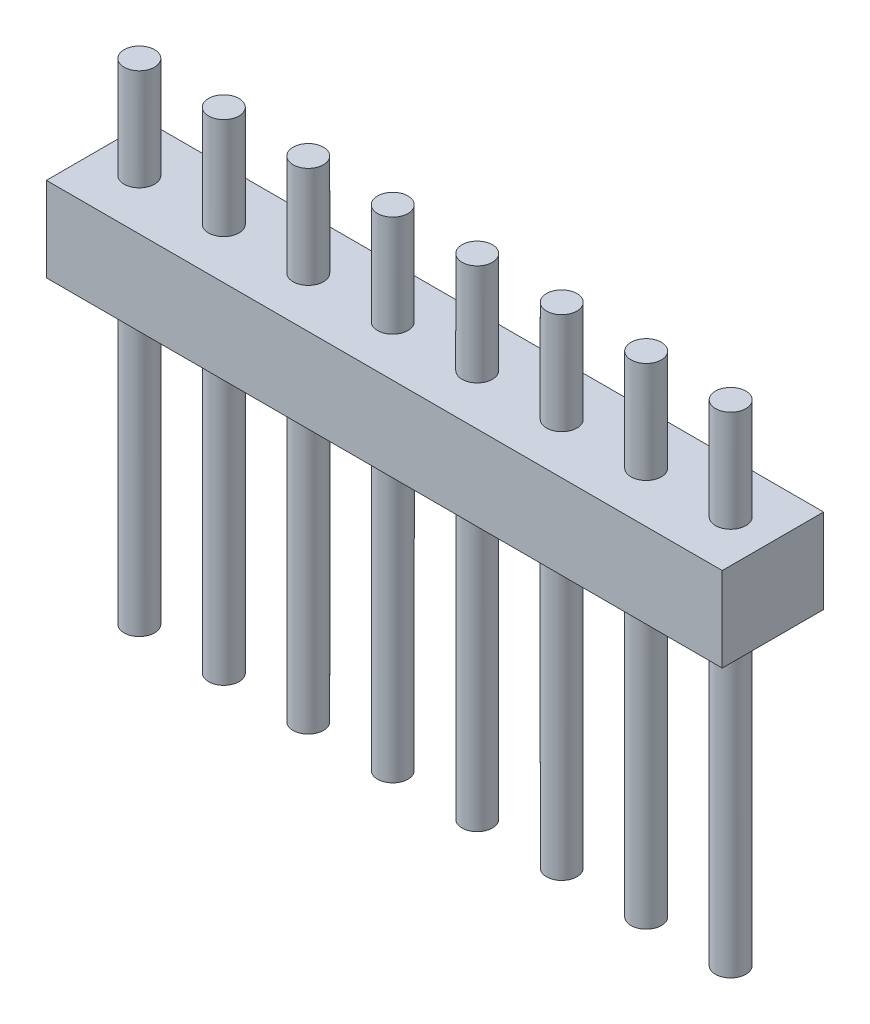
from build123d import *

# Parameters (mm, degrees)
CROQUIS1_W              = 20
CROQUIS1_H              = 2.5
SALIENTE_EXTRUIR1_DEPTH = 3
CROQUIS2_R              = 0.45
SALIENTE_EXTRUIR2_DEPTH = 3
CROQUIS3_R              = 0.45
SALIENTE_EXTRUIR3_DEPTH = 9


with BuildPart() as part:
    # Croquis1 → Saliente-Extruir1 (new body)
    with BuildSketch(Plane.XY):
        Rectangle(CROQUIS1_W, CROQUIS1_H)
    extrude(amount=SALIENTE_EXTRUIR1_DEPTH)

    # Croquis2 → Saliente-Extruir2 (add)
    with BuildSketch(Plane(origin=(0, 1.25, 0), x_dir=(1, 0, 0), z_dir=(0, 1, 0))):
        with Locations((-8.75, -1.5)):
            Circle(CROQUIS2_R)
        with Locations((-6.25, -1.5)):
            Circle(CROQUIS2_R)
        with Locations((-3.75, -1.5)):
            Circle(CROQUIS2_R)
        with Locations((-1.25, -1.5)):
            Circle(CROQUIS2_R)
        with Locations((1.25, -1.5)):
            Circle(CROQUIS2_R)
        with Locations((3.75, -1.5)):
            Circle(CROQUIS2_R)
        with Locations((6.25, -1.5)):
            Circle(CROQUIS2_R)
        with Locations((8.75, -1.5)):
            Circle(CROQUIS2_R)
    extrude(amount=SALIENTE_EXTRUIR2_DEPTH)

    # Croquis3 → Saliente-Extruir3 (add)
    with BuildSketch(Plane.XZ.offset(1.25)):
        with Locations((-8.75, 1.5)):
            Circle(CROQUIS3_R)
        with Locations((-6.25, 1.5)):
            Circle(CROQUIS3_R)
        with Locations((-3.75, 1.5)):
            Circle(CROQUIS3_R)
        with Locations((-1.25, 1.5)):
            Circle(CROQUIS3_R)
        with Locations((1.25, 1.5)):
            Circle(CROQUIS3_R)
        with Locations((3.75, 1.5)):
            Circle(CROQUIS3_R)
        with Locations((6.25, 1.5)):
            Circle(CROQUIS3_R)
        with Locations((8.75, 1.5)):
            Circle(CROQUIS3_R)
    extrude(amount=SALIENTE_EXTRUIR3_DEPTH)


solid = part.part
